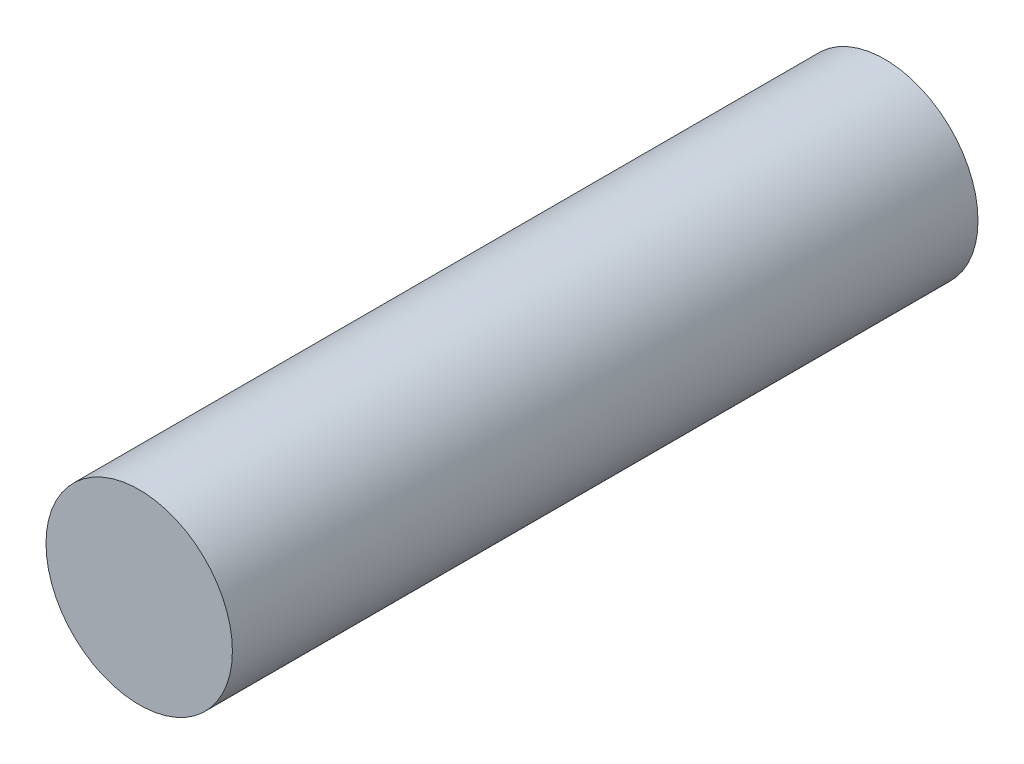
from build123d import *

# Parameters (mm, degrees)
SKETCH1_R          = 4.7625
BASE_EXTRUDE_DEPTH = 38.1


with BuildPart() as part:
    # Sketch1 → Base-Extrude (new body)
    with BuildSketch(Plane.XY):
        Circle(SKETCH1_R)
    extrude(amount=BASE_EXTRUDE_DEPTH)


solid = part.part
